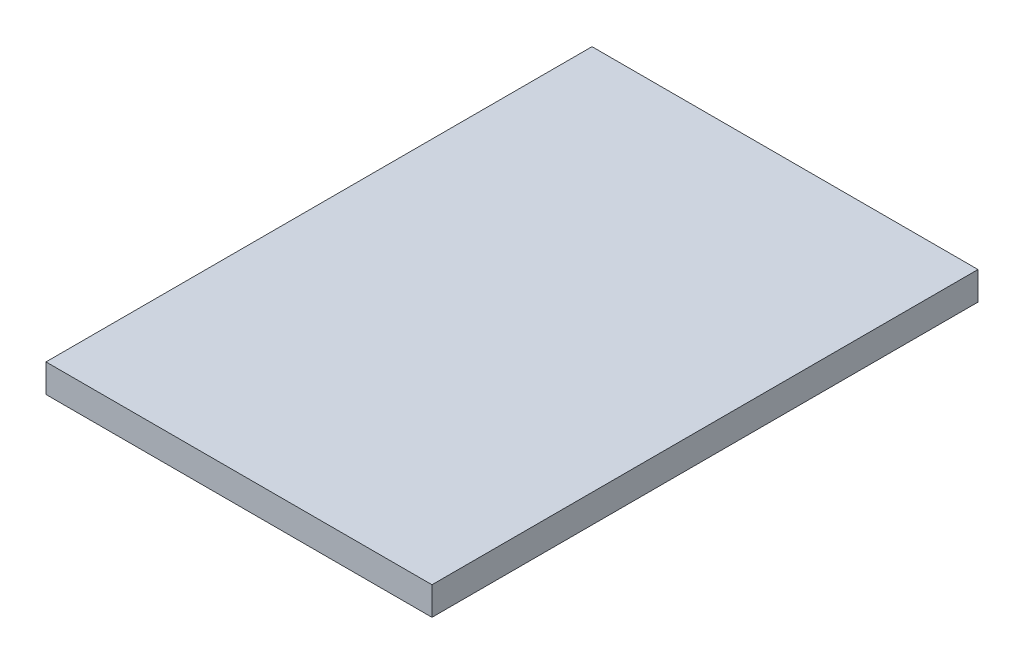
from build123d import *

# Parameters (mm, degrees)
ESQUISSE1_W        = 410
ESQUISSE1_H        = 30
BOSS_EXTRU_1_DEPTH = 580


with BuildPart() as part:
    # Esquisse1 → Boss.-Extru.1 (new body)
    with BuildSketch(Plane.XY):
        with Locations((175, 15)):
            Rectangle(ESQUISSE1_W, ESQUISSE1_H)
    extrude(amount=BOSS_EXTRU_1_DEPTH)


solid = part.part
